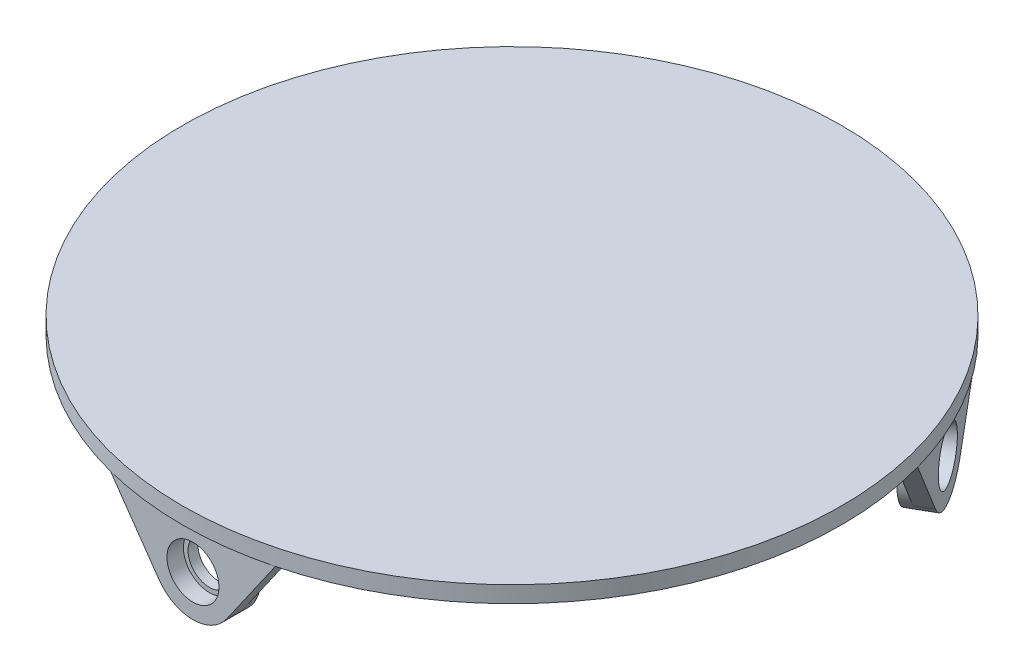
from build123d import *

# Parameters (mm, degrees)
SKETCH1_R           = 100
BOSS_EXTRUDE2_DEPTH = 5
SKETCH4_W           = 50
SKETCH4_H           = 5
BOSS_EXTRUDE4_DEPTH = 30
SKETCH6_R           = 7.89
CUT_EXTRUDE1_DEPTH  = 5
CIRPATTERN2_COUNT   = 3
SKETCH8_R           = 12.5
SKETCH8_R_2         = 6.5
BOSS_EXTRUDE5_DEPTH = 3
CIRPATTERN3_COUNT   = 3


with BuildPart() as part:
    # Sketch1 → Boss-Extrude2 (new body)
    with BuildSketch(Plane(origin=(0, 0, 0), x_dir=(1, 0, 0), z_dir=(0, 1, 0))):
        Circle(SKETCH1_R)
    extrude(amount=BOSS_EXTRUDE2_DEPTH)

    # Sketch4 → Boss-Extrude4 (add)
    with BuildSketch(Plane.XZ):
        with Locations((0, 94.324583655)):
            Rectangle(SKETCH4_W, SKETCH4_H)
    boss_extrude4 = extrude(amount=BOSS_EXTRUDE4_DEPTH)

    # Sketch6 → Cut-Extrude1 (cut)
    with BuildSketch(Plane(origin=(0, 0, 91.824583655), x_dir=(-1, 0, 0), z_dir=(0, 0, -1))):
        with Locations((0, -14)):
            Circle(SKETCH6_R)
        with BuildLine():
            Line((25, 0), (10.253630426, -21.149340046))
            ThreePointArc((10.253630426, -21.149340046), (0, -26.5), (-10.253630426, -21.149340046))
            Line((-10.253630426, -21.149340046), (-25, 0))
            Line((-25, 0), (-25, -30.813240721))
            Line((-25, -30.813240721), (25, -30.813240721))
            Line((25, -30.813240721), (25, 0))
        make_face()
    cut_extrude1 = extrude(amount=-CUT_EXTRUDE1_DEPTH, mode=Mode.SUBTRACT)

    # CirPattern2: Boss-Extrude4, Cut-Extrude1 ×3 about axis
    cirpattern2_axis = Axis((0, 0, 0), (0, 1, 0))
    for i in range(1, CIRPATTERN2_COUNT):
        add(boss_extrude4.rotate(cirpattern2_axis, i * 360 / CIRPATTERN2_COUNT))
        add(cut_extrude1.rotate(cirpattern2_axis, i * 360 / CIRPATTERN2_COUNT), mode=Mode.SUBTRACT)

    # Sketch8 → Boss-Extrude5 (add)
    with BuildSketch(Plane(origin=(0, 0, 91.824583655), x_dir=(-1, 0, 0), z_dir=(0, 0, -1))):
        with Locations((0, -14)):
            Circle(SKETCH8_R)
        with Locations((0, -14)):
            Circle(SKETCH8_R_2, mode=Mode.SUBTRACT)
    boss_extrude5 = extrude(amount=BOSS_EXTRUDE5_DEPTH)

    # CirPattern3: Boss-Extrude5 ×3 about axis
    cirpattern3_axis = Axis((0, 0, 0), (0, 1, 0))
    for i in range(1, CIRPATTERN3_COUNT):
        add(boss_extrude5.rotate(cirpattern3_axis, i * 360 / CIRPATTERN3_COUNT))


solid = part.part
